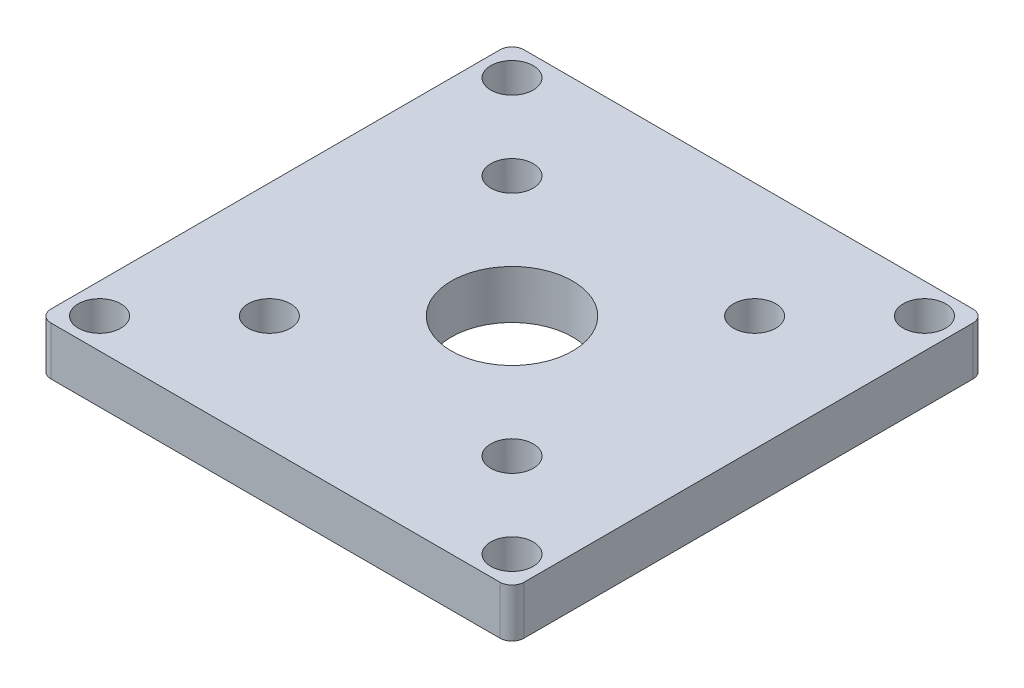
from build123d import *

# Parameters (mm, degrees)
SKETCH1_W           = 39
SKETCH1_H           = 39
SKETCH1_R           = 1.75
BOSS_EXTRUDE1_DEPTH = 4
SKETCH2_R           = 1.75
CUT_EXTRUDE1_DEPTH  = 11
FILLET1_R           = 1
CUT_EXTRUDE2_REACH  = 6
SKETCH3_R           = 5


with BuildPart() as part:
    # Sketch1 → Boss-Extrude1 (new body)
    with BuildSketch(Plane(origin=(0, 0, 0), x_dir=(1, 0, 0), z_dir=(0, 1, 0))):
        Rectangle(SKETCH1_W, SKETCH1_H)
        with Locations((17, 17)):
            Circle(SKETCH1_R, mode=Mode.SUBTRACT)
        with Locations((17, -17)):
            Circle(SKETCH1_R, mode=Mode.SUBTRACT)
        with Locations((-17, -17)):
            Circle(SKETCH1_R, mode=Mode.SUBTRACT)
        with Locations((-17, 17)):
            Circle(SKETCH1_R, mode=Mode.SUBTRACT)
    extrude(amount=BOSS_EXTRUDE1_DEPTH)

    # Sketch2 → Cut-Extrude1 (cut)
    with BuildSketch(Plane(origin=(0, 4, 0), x_dir=(1, 0, 0), z_dir=(0, 1, 0))):
        with Locations((10, 10)):
            Circle(SKETCH2_R)
        with Locations((10, -10)):
            Circle(SKETCH2_R)
        with Locations((-10, -10)):
            Circle(SKETCH2_R)
        with Locations((-10, 10)):
            Circle(SKETCH2_R)
    extrude(amount=-CUT_EXTRUDE1_DEPTH, mode=Mode.SUBTRACT)

    # Fillet1
    fillet1_edges = [part.edges().sort_by_distance(p)[0] for p in [
        (19.5, 2, 19.5),
        (-19.5, 2, 19.5),
        (-19.5, 2, -19.5),
        (19.5, 2, -19.5),
    ]]
    fillet(fillet1_edges, radius=FILLET1_R)

    # Sketch3 → Cut-Extrude2 (cut, up to next)
    with BuildSketch(Plane(origin=(0, 4, 0), x_dir=(1, 0, 0), z_dir=(0, 1, 0)), mode=Mode.PRIVATE) as cut_extrude2_sk1:
        Circle(SKETCH3_R)
    cut_extrude2_tool1 = extrude(cut_extrude2_sk1.sketch, amount=-CUT_EXTRUDE2_REACH, mode=Mode.PRIVATE) & part.part
    add(cut_extrude2_tool1.solids().sort_by_distance((0, 4, 0))[0], mode=Mode.SUBTRACT)


solid = part.part
